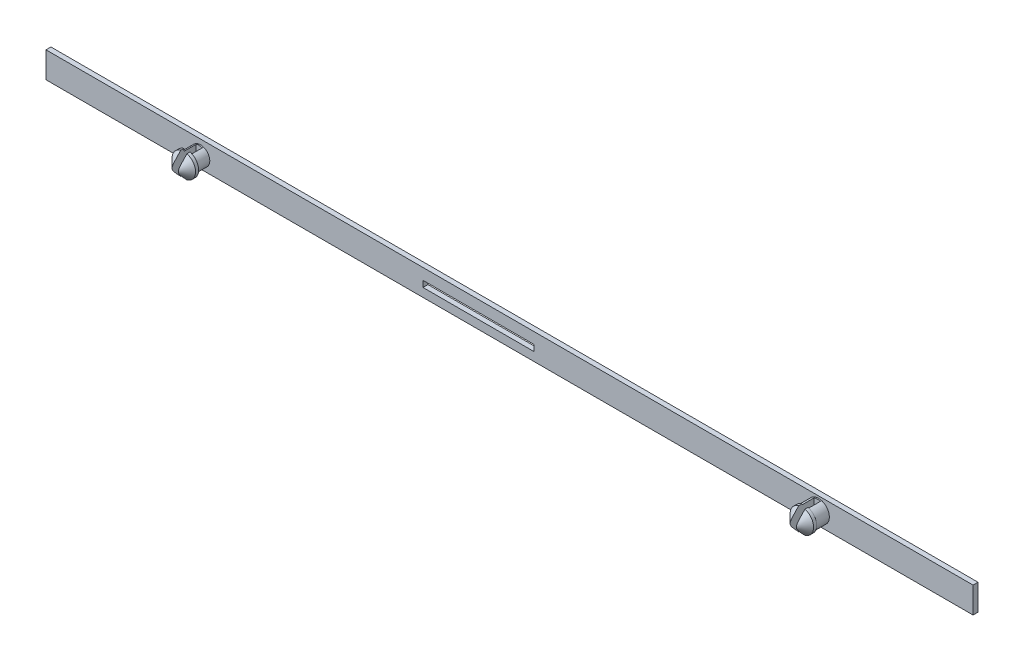
from build123d import *

# Parameters (mm, degrees)
SKICA2_W                 = 150
SKICA2_H                 = 4.2
SKICA2_W_2               = 18
SKICA2_H_2               = 1
P_IDAT_VYSUNUT_M2_DEPTH  = 0.8
SKICA3_R                 = 1.5
SKICA3_R_2               = 1.75
P_IDAT_VYSUNUT_M3_DEPTH  = 2.2
SKICA5_R                 = 1.9
P_IDAT_VYSUNUT_M5_DEPTH  = 2
ZKOSEN_2_SIZE            = 1.5
SKICA7_W                 = 1
SKICA7_H                 = 5
ODEBRAT_VYSUNUT_M1_DEPTH = 4


with BuildPart() as part:
    # Skica2 → Přidat vysunutím2 (new body)
    with BuildSketch(Plane.XY):
        Rectangle(SKICA2_W, SKICA2_H)
        with Locations((-5, -0.2)):
            Rectangle(SKICA2_W_2, SKICA2_H_2, mode=Mode.SUBTRACT)
    extrude(amount=P_IDAT_VYSUNUT_M2_DEPTH)

    # Skica3 → Přidat vysunutím3 (add)
    with BuildSketch(Plane.XY.offset(0.8)):
        with Locations((-50, -0.2)):
            Circle(SKICA3_R)
        with Locations((50, 0)):
            Circle(SKICA3_R_2)
    extrude(amount=P_IDAT_VYSUNUT_M3_DEPTH)

    # Skica5 → Přidat vysunutím5 (add)
    with BuildSketch(Plane.XY.offset(3)):
        with Locations((-50, -0.2)):
            Circle(SKICA5_R)
        with Locations((50, 0)):
            Circle(SKICA5_R)
    extrude(amount=P_IDAT_VYSUNUT_M5_DEPTH)

    # Zkosení2
    zkosen_2_edges = [part.edges().sort_by_distance(p)[0] for p in [
        (-51.9, -0.2, 5),
        (48.1, 0, 5),
    ]]
    chamfer(zkosen_2_edges, length=ZKOSEN_2_SIZE)

    # Skica7 → Odebrat vysunutím1 (cut)
    with BuildSketch(Plane.XY.offset(5)):
        with Locations((-50, -0.2)):
            Rectangle(SKICA7_W, SKICA7_H)
        with Locations((50, 0)):
            Rectangle(SKICA7_W, SKICA7_H)
    extrude(amount=-ODEBRAT_VYSUNUT_M1_DEPTH, mode=Mode.SUBTRACT)


solid = part.part
